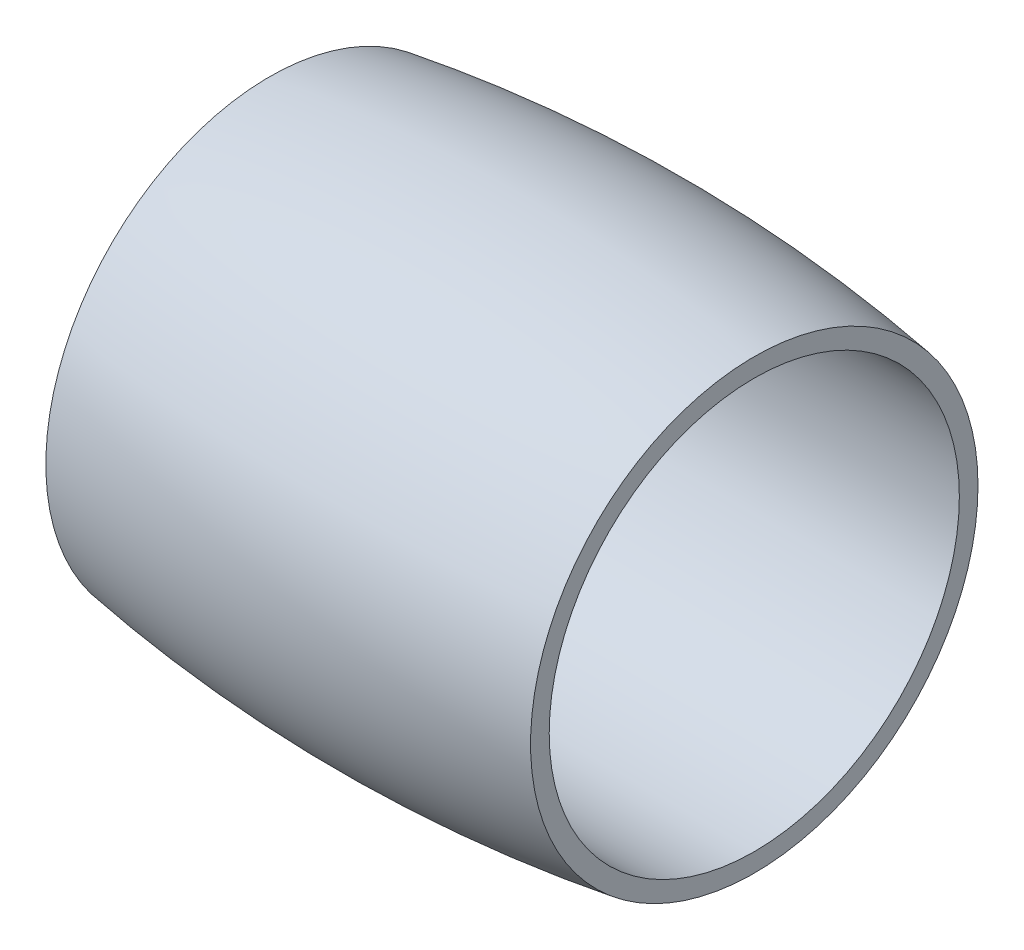
from build123d import *


with BuildPart() as part:
    # Skizze2 → Rotation1 (revolve)
    with BuildSketch(Plane.XY):
        with BuildLine():
            Line((-32.5, 27.5), (32.5, 27.5))
            Line((32.5, 27.5), (32.5, 30))
            ThreePointArc((32.5, 30), (0, 32.5), (-32.5, 30))
            Line((-32.5, 30), (-32.5, 27.5))
        make_face()
    revolve(axis=Axis((35.75, 0, 0), (-1, 0, 0)))


solid = part.part
